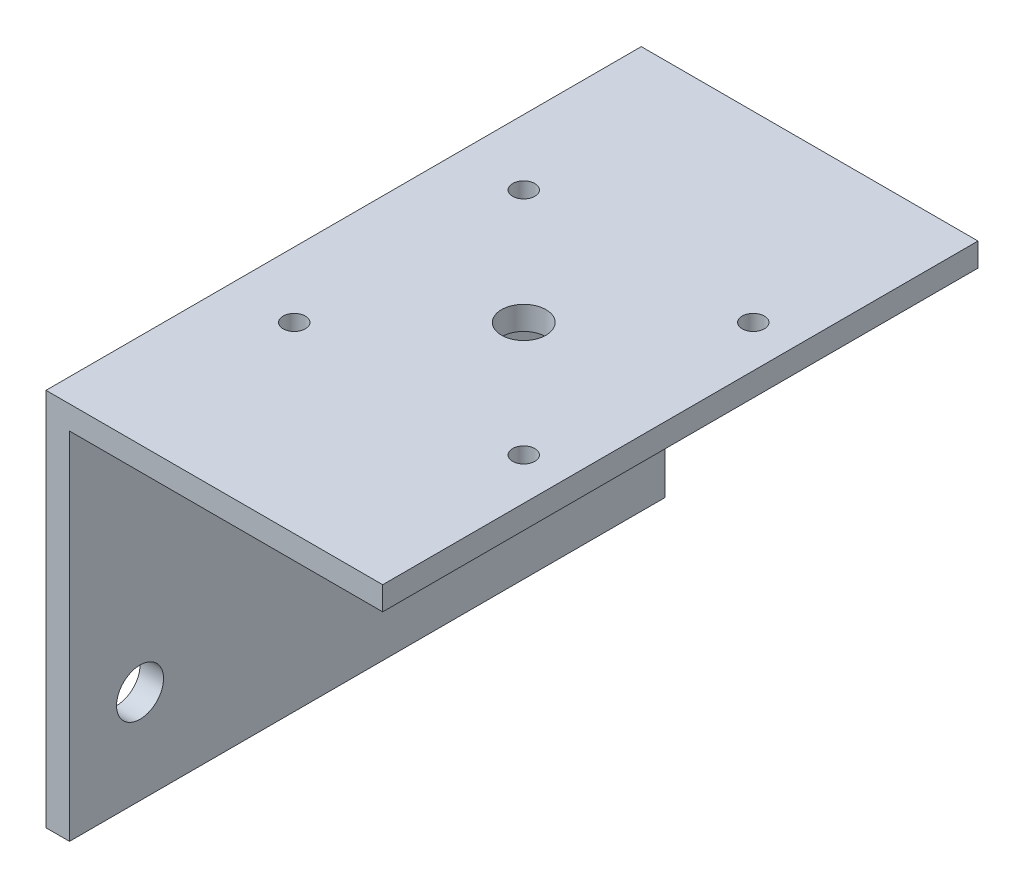
from build123d import *

# Parameters (mm, degrees)
BOSS_EXTRUDE1_DEPTH = 80.4
SKETCH2_R           = 3.175
CUT_EXTRUDE1_DEPTH  = 4.175
SKETCH3_R           = 1.5
SKETCH3_R_2         = 3
CUT_EXTRUDE2_DEPTH  = 52.175


with BuildPart() as part:
    # Sketch1 → Boss-Extrude1 (new body)
    with BuildSketch(Plane.XY):
        Polygon((0, 0), (3.175, 0), (3.175, 48), (45.475, 48), (45.475, 51.175), (0, 51.175), align=None)
    extrude(amount=BOSS_EXTRUDE1_DEPTH)

    # Sketch2 → Cut-Extrude1 (cut, through all)
    with BuildSketch(Plane(origin=(3.175, 0, 0), x_dir=(0, 0, -1), z_dir=(1, 0, 0))):
        with Locations((-70.875, 12.7)):
            Circle(SKETCH2_R)
        with Locations((-9.525, 12.7)):
            Circle(SKETCH2_R)
    extrude(amount=-CUT_EXTRUDE1_DEPTH, mode=Mode.SUBTRACT)

    # Sketch3 → Cut-Extrude2 (cut, through all)
    with BuildSketch(Plane(origin=(0, 51.175, 0), x_dir=(1, 0, 0), z_dir=(0, 1, 0))):
        with Locations((39.825, -55.7)):
            Circle(SKETCH3_R)
        with Locations((8.825, -55.7)):
            Circle(SKETCH3_R)
        with Locations((8.825, -24.7)):
            Circle(SKETCH3_R)
        with Locations((39.825, -24.7)):
            Circle(SKETCH3_R)
        with Locations((24.325, -40.2)):
            Circle(SKETCH3_R_2)
    extrude(amount=-CUT_EXTRUDE2_DEPTH, mode=Mode.SUBTRACT)


solid = part.part
